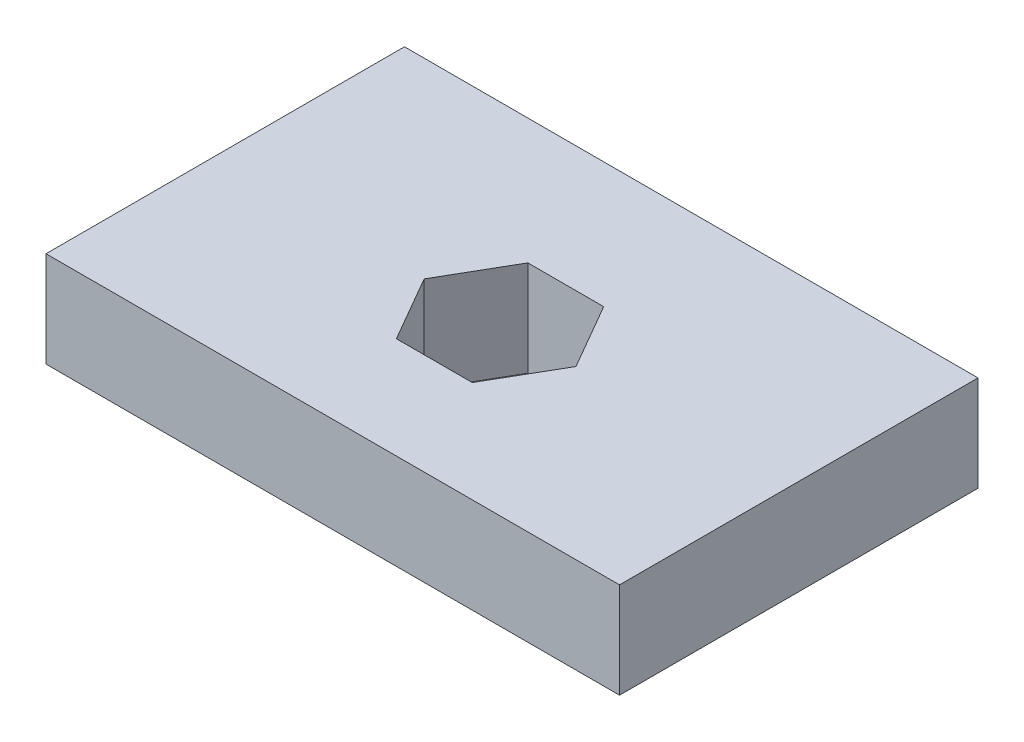
from build123d import *

# Parameters (mm, degrees)
SKETCH1_W           = 76.2
SKETCH1_H           = 47.625
BOSS_EXTRUDE1_DEPTH = 12.7
SKETCH2_R           = 3.175
CUT_EXTRUDE1_DEPTH  = 25.4


with BuildPart() as part:
    # Sketch1 → Boss-Extrude1 (new body)
    with BuildSketch(Plane(origin=(0, 0, 0), x_dir=(1, 0, 0), z_dir=(0, 1, 0))):
        with Locations((0, 1.5875)):
            Rectangle(SKETCH1_W, SKETCH1_H)
        Polygon((10.081979076, 0), (5.040989538, 8.73125), (-5.040989538, 8.73125), (-10.081979076, 0), (-5.040989538, -8.73125), (5.040989538, -8.73125), align=None, mode=Mode.SUBTRACT)
    extrude(amount=BOSS_EXTRUDE1_DEPTH)

    # Sketch2 → Cut-Extrude1 (cut)
    with BuildSketch(Plane(origin=(0, 0, -25.4), x_dir=(-1, 0, 0), z_dir=(0, 0, -1))):
        with Locations((-25.4, 6.35)):
            Circle(SKETCH2_R)
        with Locations((25.4, 6.35)):
            Circle(SKETCH2_R)
    extrude(amount=-CUT_EXTRUDE1_DEPTH, mode=Mode.SUBTRACT)


solid = part.part
